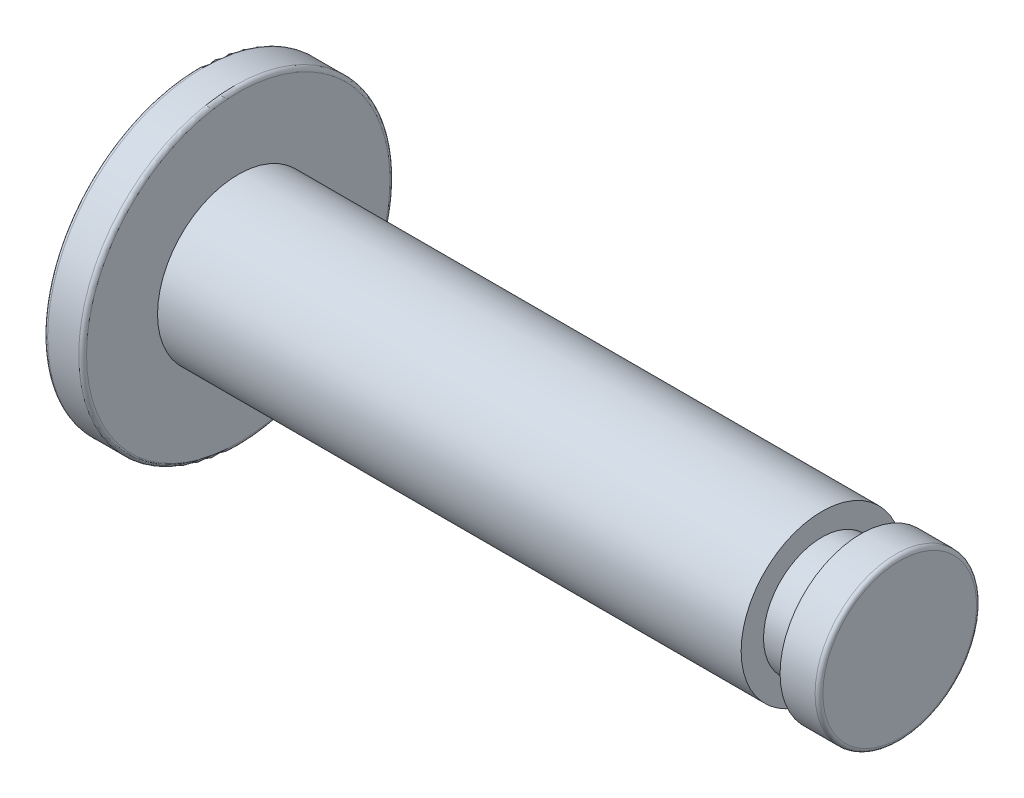
from build123d import *

# Parameters (mm, degrees)
FILLET1_R = 0.1


with BuildPart() as part:
    # Sketch1 → Revolve1 (revolve)
    with BuildSketch(Plane.XY):
        Polygon((0, 0), (0, 4), (1, 4), (1, 2.075), (16, 2.075), (16, 1.5), (17, 1.5), (17, 2.075), (18, 2.075), (18, 0), align=None)
    revolve(axis=Axis((-1.619660583, 0, 0), (1, 0, 0)))

    # Fillet1
    fillet1_edges = [part.edges().sort_by_distance(p)[0] for p in [
        (1, -4, 0),
        (0, -4, 0),
        (18, -2.075, 0),
    ]]
    fillet(fillet1_edges, radius=FILLET1_R)


solid = part.part
